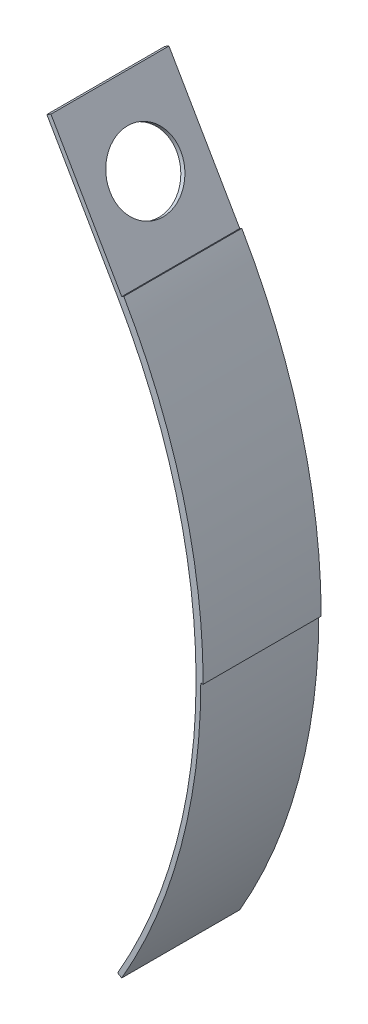
from build123d import *

# Parameters (mm, degrees)
EXTRUDE_1_DEPTH     = 5
SKETCH_2_R          = 1.5
CUT_EXTRUDE_1_DEPTH = 6.698711306
EXTRUDE_2_DEPTH     = 5


with BuildPart() as part:
    # 草图1 → 拉伸-薄壁1 (new body)
    with BuildSketch(Plane.XY):
        with BuildLine():
            ThreePointArc((0, -25), (3.349364905, -12.5), (0, 0))
            Line((0, 0), (-3, 5.196152423))
            Line((-3, 5.196152423), (-3.173205081, 5.096152423))
            Line((-3.173205081, 5.096152423), (-0.173205081, -0.1))
            ThreePointArc((-0.173205081, -0.1), (3.149364905, -12.5), (-0.173205081, -24.9))
            Line((-0.173205081, -24.9), (0, -25))
        make_face()
    extrude(amount=EXTRUDE_1_DEPTH)

    # 草图2 → 切除-拉伸1 (cut, through all)
    with BuildSketch(Plane(origin=(-0.173205081, -0.1, 0), x_dir=(0, 0, 1), z_dir=(-0.866025404, -0.5, 0))):
        with Locations((2.5, 3)):
            Circle(SKETCH_2_R)
    extrude(amount=-CUT_EXTRUDE_1_DEPTH, mode=Mode.SUBTRACT)

    # 草图3 → 拉伸-薄壁2 (add)
    with BuildSketch(Plane.XY):
        with BuildLine():
            ThreePointArc((0, 0), (2.497510563, -6.029523872), (3.349364905, -12.5))
            Line((3.349364905, -12.5), (3.449364905, -12.5))
            ThreePointArc((3.449364905, -12.5), (2.594103145, -6.003641968), (0.08660254, 0.05))
            Line((0.08660254, 0.05), (0, 0))
        make_face()
    extrude(amount=EXTRUDE_2_DEPTH)


solid = part.part
